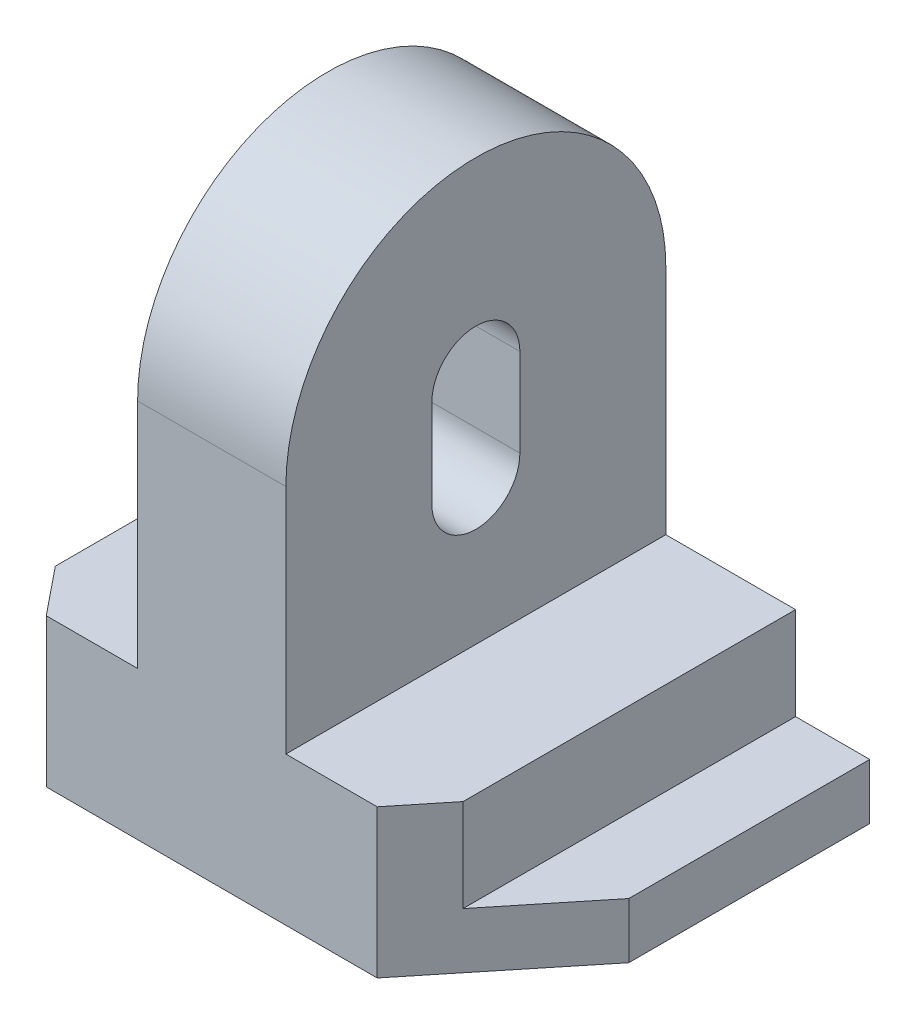
from build123d import *

# Parameters (mm, degrees)
BOSS_EXTRUDE1_DEPTH = 82
CHAMFER6_SIZE       = 30
CHAMFER6_SIZE2      = 24.293520996
CHAMFER7_SIZE       = 30
CHAMFER7_SIZE2      = 24.293520996
CUT_EXTRUDE2_DEPTH  = 82


with BuildPart() as part:
    # Sketch1 → Boss-Extrude1 (new body)
    with BuildSketch(Plane.XY):
        Polygon((-60, 0), (60, 0), (60, 12), (44, 12), (44, 32), (16, 32), (16, 123), (-16, 123), (-16, 32), (-44, 32), (-44, 12), (-60, 12), align=None)
    extrude(amount=BOSS_EXTRUDE1_DEPTH)

    # Chamfer6
    chamfer6_edges = [part.edges().sort_by_distance(p)[0] for p in [
        (60, 6, 82),
    ]]
    chamfer6_side = [part.faces().sort_by_distance(p)[0] for p in [
        (60, 6, 41),
    ]]
    chamfer(chamfer6_edges, length=CHAMFER6_SIZE, length2=CHAMFER6_SIZE2, reference=chamfer6_side[0])

    # Chamfer7
    chamfer7_edges = [part.edges().sort_by_distance(p)[0] for p in [
        (-60, 6, 82),
    ]]
    chamfer7_side = [part.faces().sort_by_distance(p)[0] for p in [
        (-60, 6, 41),
    ]]
    chamfer(chamfer7_edges, length=CHAMFER7_SIZE, length2=CHAMFER7_SIZE2, reference=chamfer7_side[0])

    # Sketch8 → Cut-Extrude2 (cut)
    with BuildSketch(Plane(origin=(16, 0, 0), x_dir=(0, 0, -1), z_dir=(1, 0, 0))):
        with BuildLine():
            Line((-82, 123), (-82, 82))
            ThreePointArc((-82, 82), (-69.991378029, 110.991378029), (-41, 123))
            Line((-41, 123), (-82, 123))
        make_face()
        with BuildLine():
            ThreePointArc((-31.5, 82), (-41, 91.5), (-50.5, 82))
            Line((-50.5, 82), (-50.5, 63))
            ThreePointArc((-50.5, 63), (-41, 53.5), (-31.5, 63))
            Line((-31.5, 63), (-31.5, 82))
        make_face()
        with BuildLine():
            Line((0, 123), (-41, 123))
            ThreePointArc((-41, 123), (-12.008621971, 110.991378029), (0, 82))
            Line((0, 82), (0, 123))
        make_face()
    extrude(amount=-CUT_EXTRUDE2_DEPTH, mode=Mode.SUBTRACT)


solid = part.part
